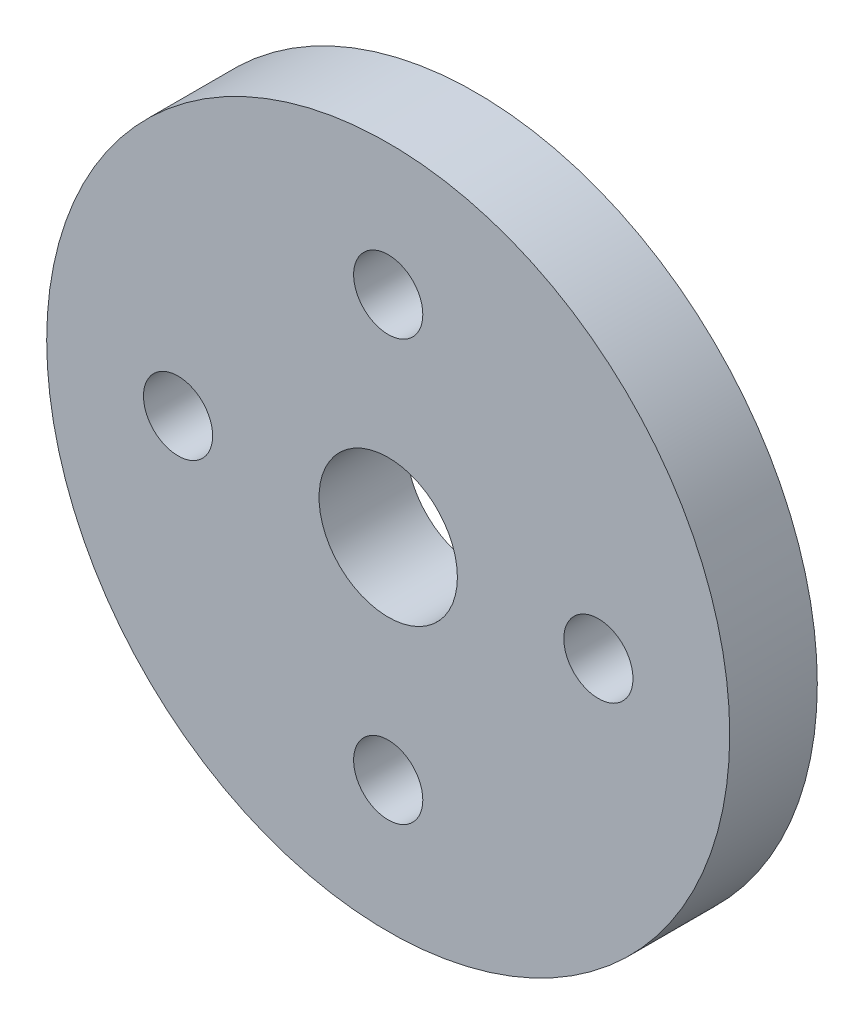
from build123d import *

# Parameters (mm, degrees)
SKETCH1_R           = 19.5
SKETCH1_R_2         = 3.95
SKETCH1_R_3         = 1.975
BOSS_EXTRUDE1_DEPTH = 5


with BuildPart() as part:
    # Sketch1 → Boss-Extrude1 (new body)
    with BuildSketch(Plane.XY):
        Circle(SKETCH1_R)
        Circle(SKETCH1_R_2, mode=Mode.SUBTRACT)
        with Locations((0, 12)):
            Circle(SKETCH1_R_3, mode=Mode.SUBTRACT)
        with Locations((12, 0)):
            Circle(SKETCH1_R_3, mode=Mode.SUBTRACT)
        with Locations((0, -12)):
            Circle(SKETCH1_R_3, mode=Mode.SUBTRACT)
        with Locations((-12, 0)):
            Circle(SKETCH1_R_3, mode=Mode.SUBTRACT)
    extrude(amount=BOSS_EXTRUDE1_DEPTH)


solid = part.part
